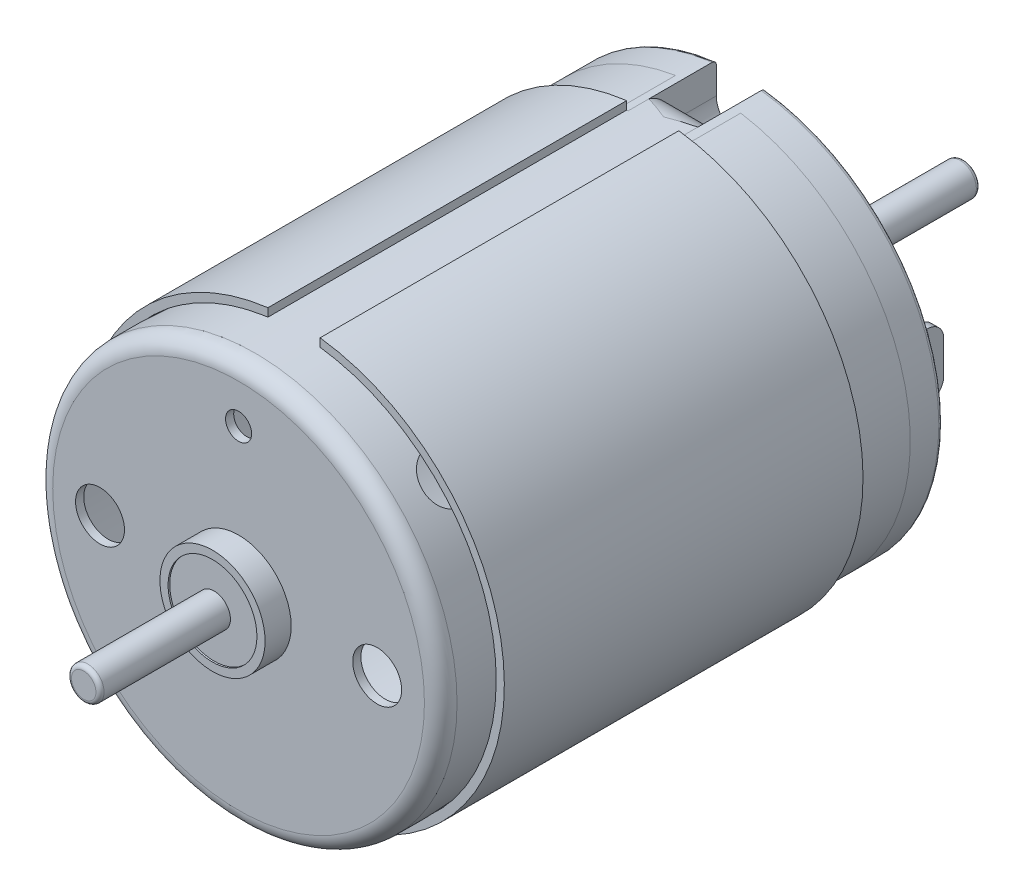
from build123d import *

# Parameters (mm, degrees)
SKETCH1_R            = 12.4
BASE_DEPTH           = 28.8
SKETCH2_R            = 12.4
BOSS_EXTRUDE2_DEPTH  = 2
SKETCH3_R            = 1
BOSS_EXTRUDE3_DEPTH  = 1.7
SKETCH4_R            = 0.75
CUT_EXTRUDE1_DEPTH   = 0.5
CUT_EXTRUDE2_DEPTH   = 5.4
BOSS_EXTRUDE4_DEPTH  = 5.4
BOSS_EXTRUDE5_DEPTH  = 1
BOSS_EXTRUDE15_DEPTH = 1.5
SKETCH14_R           = 13.384753183
SKETCH14_R_2         = 12.4
CUT_EXTRUDE3_DEPTH   = 33.5
FILLET2_R            = 1
FILLET2_OF_MIRROR2_R = 1
SKETCH15_W           = 0.5
SKETCH15_H           = 4
BOSS_EXTRUDE16_DEPTH = 4
SKETCH16_R           = 0.75
CUT_EXTRUDE4_DEPTH   = 0.5
FILLET3_R            = 1
SKETCH17_R           = 1
ENCODER_SHAFT_DEPTH  = 13.7
FILLET4_R            = 1
SKETCH18_R           = 3.225
SKETCH18_R_2         = 2.725
BOSS_EXTRUDE18_DEPTH = 1.6
SKETCH19_R           = 2.725
SKETCH19_R_2         = 1
BOSS_EXTRUDE19_DEPTH = 1.5
SKETCH20_R           = 0.8
SKETCH20_R_2         = 1.5
CUT_EXTRUDE5_DEPTH   = 0.5
SKETCH21_R           = 11.9
CUT_EXTRUDE6_DEPTH   = 23.5
SKETCH22_R           = 1
FRONT_SHAFT_DEPTH    = 9.5
SKETCH24_R           = 12.9
SKETCH24_R_2         = 12.4
BOSS_EXTRUDE21_DEPTH = 22
CUT_EXTRUDE8_DEPTH   = 22
CUT_EXTRUDE11_START  = -19.243354955
SKETCH26_R           = 1.5
CUT_EXTRUDE11_DEPTH  = 38.41627544
CIRPATTERN1_COUNT    = 2
CIRPATTERN1_ANGLE    = 90
FILLET5_R            = 0.25
FILLET6_R            = 0.25
FILLET7_R            = 0.25


with BuildPart() as part:
    # Sketch1 → Base (new body)
    with BuildSketch(Plane.XY):
        Circle(SKETCH1_R)
    extrude(amount=BASE_DEPTH)


with BuildPart() as body_2:
    # Sketch2 → Boss-Extrude2 (new body)
    with BuildSketch(Plane(origin=(0, 0, 0), x_dir=(-1, 0, 0), z_dir=(0, 0, -1))):
        Circle(SKETCH2_R)
    extrude(amount=BOSS_EXTRUDE2_DEPTH)

    # Sketch3 → Boss-Extrude3 (add)
    with BuildSketch(Plane(origin=(0, 0, -2), x_dir=(-1, 0, 0), z_dir=(0, 0, -1))):
        with BuildLine():
            Line((-1.436140662, 4), (1.436140662, 4))
            ThreePointArc((1.436140662, 4), (4.25, 0), (1.436140662, -4))
            Line((1.436140662, -4), (-1.436140662, -4))
            ThreePointArc((-1.436140662, -4), (-4.25, 0), (-1.436140662, 4))
        make_face()
        Circle(SKETCH3_R, mode=Mode.SUBTRACT)
    extrude(amount=BOSS_EXTRUDE3_DEPTH)

    # Sketch4 → Cut-Extrude1 (cut)
    with BuildSketch(Plane(origin=(0, 0, -2), x_dir=(-1, 0, 0), z_dir=(0, 0, -1))):
        with Locations((0, -5.203617714)):
            Circle(SKETCH4_R)
        with Locations((0, 5.203617714)):
            Circle(SKETCH4_R)
        with BuildLine():
            Line((-2, 7.071067812), (-2, 4.898979486))
            ThreePointArc((-2, 4.898979486), (-2.073598567, 4.637863002), (-2.272727273, 4.453617714))
            ThreePointArc((-2.272727273, 4.453617714), (-5, 0), (-2.272727273, -4.453617714))
            ThreePointArc((-2.272727273, -4.453617714), (-2.073598567, -4.637863002), (-2, -4.898979486))
            Line((-2, -4.898979486), (-2, -7.071067812))
            ThreePointArc((-2, -7.071067812), (-2.211324865, -7.479316102), (-2.666666667, -7.542472333))
            ThreePointArc((-2.666666667, -7.542472333), (-5.010229516, -6.236794064), (-6.790369935, -4.229760766))
            Line((-6.790369935, -4.229760766), (-9.5, -4.229760766))
            ThreePointArc((-9.5, -4.229760766), (-9.853553391, -4.083314157), (-10, -3.729760766))
            Line((-10, -3.729760766), (-10, 3.729760766))
            ThreePointArc((-10, 3.729760766), (-9.853553391, 4.083314157), (-9.5, 4.229760766))
            Line((-9.5, 4.229760766), (-6.790369935, 4.229760766))
            ThreePointArc((-6.790369935, 4.229760766), (-5.010229516, 6.236794064), (-2.666666667, 7.542472333))
            ThreePointArc((-2.666666667, 7.542472333), (-2.211324865, 7.479316102), (-2, 7.071067812))
        make_face()
        with BuildLine():
            Line((6.790369935, -4.229760766), (9.5, -4.229760766))
            ThreePointArc((9.5, -4.229760766), (9.853553391, -4.083314157), (10, -3.729760766))
            Line((10, -3.729760766), (10, 3.729760766))
            ThreePointArc((10, 3.729760766), (9.853553391, 4.083314157), (9.5, 4.229760766))
            Line((9.5, 4.229760766), (6.790369935, 4.229760766))
            ThreePointArc((6.790369935, 4.229760766), (5.010229516, 6.236794064), (2.666666667, 7.542472333))
            ThreePointArc((2.666666667, 7.542472333), (2.211324865, 7.479316102), (2, 7.071067812))
            Line((2, 7.071067812), (2, 4.898979486))
            ThreePointArc((2, 4.898979486), (2.073598567, 4.637863002), (2.272727273, 4.453617714))
            ThreePointArc((2.272727273, 4.453617714), (5, 0), (2.272727273, -4.453617714))
            ThreePointArc((2.272727273, -4.453617714), (2.073598567, -4.637863002), (2, -4.898979486))
            Line((2, -4.898979486), (2, -7.071067812))
            ThreePointArc((2, -7.071067812), (2.211324865, -7.479316102), (2.666666667, -7.542472333))
            ThreePointArc((2.666666667, -7.542472333), (5.010229516, -6.236794064), (6.790369935, -4.229760766))
        make_face()
    extrude(amount=-CUT_EXTRUDE1_DEPTH, mode=Mode.SUBTRACT)


with BuildPart() as cut_extrude2_tool:
    # Sketch5 → Cut-Extrude2 (new body)
    with BuildSketch(Plane(origin=(0, 0, -2), x_dir=(-1, 0, 0), z_dir=(0, 0, -1))):
        with BuildLine():
            Line((-2, 12.237646833), (-2, 10.4))
            ThreePointArc((-2, 10.4), (0, 8.4), (2, 10.4))
            Line((2, 10.4), (2, 12.237646833))
            ThreePointArc((2, 12.237646833), (0, 12.4), (-2, 12.237646833))
        make_face()
        with BuildLine():
            Line((2, -10.4), (2, -12.237646833))
            ThreePointArc((2, -12.237646833), (0, -12.4), (-2, -12.237646833))
            Line((-2, -12.237646833), (-2, -10.4))
            ThreePointArc((-2, -10.4), (0, -8.4), (2, -10.4))
        make_face()
    extrude(amount=-CUT_EXTRUDE2_DEPTH)


with BuildPart() as part_1:
    add(part.part)

    # Cut-Extrude2: cut by cut_extrude2_tool
    add(cut_extrude2_tool.part, mode=Mode.SUBTRACT)

    # Sketch11 → Boss-Extrude15 (add, symmetric)
    with BuildSketch(Plane(origin=(0, 0, 0), x_dir=(0, 0, -1), z_dir=(1, 0, 0))):
        with BuildLine():
            Line((-3.4, 12.4), (-2.728427125, 12.4))
            ThreePointArc((-2.728427125, 12.4), (-1.96306026, 12.247759065), (-1.314213562, 11.814213562))
            Line((-1.314213562, 11.814213562), (0.221320344, 10.278679656))
            Line((0.221320344, 10.278679656), (-0.309009742, 9.748349571))
            Line((-0.309009742, 9.748349571), (-1.624873734, 11.064213562))
            ThreePointArc((-1.624873734, 11.064213562), (-2.273720432, 11.497759065), (-3.039087297, 11.65))
            Line((-3.039087297, 11.65), (-3.4, 11.65))
            Line((-3.4, 11.65), (-3.4, 12.4))
        make_face()
    boss_extrude15 = extrude(amount=BOSS_EXTRUDE15_DEPTH, both=True)

    # Sketch14 → Cut-Extrude3 (cut, through all)
    with BuildSketch(Plane.XY.offset(28.8)):
        Circle(SKETCH14_R)
        Circle(SKETCH14_R_2, mode=Mode.SUBTRACT)
    cut_extrude3 = extrude(amount=-CUT_EXTRUDE3_DEPTH, mode=Mode.SUBTRACT)

    # Fillet2
    fillet2_edges = [part_1.edges().sort_by_distance(p)[0] for p in [
        (-1.5, 10.013514613, 0.043844699),
        (1.5, 10.013514613, 0.043844699),
    ]]
    fillet(fillet2_edges, radius=FILLET2_R)

    # Mirror2: Boss-Extrude15 across plane
    add(boss_extrude15.mirror(Plane.ZX))

    # Mirror2 2: Cut-Extrude3 across plane
    add(cut_extrude3.mirror(Plane.ZX), mode=Mode.SUBTRACT)

    # Fillet2 of Mirror2
    fillet2_of_mirror2_edges = [part_1.edges().sort_by_distance(p)[0] for p in [
        (-1.5, -10.013514613, 0.043844699),
        (1.5, -10.013514613, 0.043844699),
    ]]
    fillet(fillet2_of_mirror2_edges, radius=FILLET2_OF_MIRROR2_R)

    # Fillet4
    fillet4_edges = [part_1.edges().sort_by_distance(p)[0] for p in [
        (-12.4, 0, 28.8),
    ]]
    fillet(fillet4_edges, radius=FILLET4_R)

    # Sketch18 → Boss-Extrude18 (add)
    with BuildSketch(Plane.XY.offset(28.8)):
        Circle(SKETCH18_R)
        Circle(SKETCH18_R_2, mode=Mode.SUBTRACT)
    extrude(amount=BOSS_EXTRUDE18_DEPTH)

    # Sketch20 → Cut-Extrude5 (cut)
    with BuildSketch(Plane.XY.offset(28.8)):
        with Locations((0, 9)):
            Circle(SKETCH20_R)
        with Locations((-8.5, 0)):
            Circle(SKETCH20_R_2)
        with Locations((8.5, 0)):
            Circle(SKETCH20_R_2)
    extrude(amount=-CUT_EXTRUDE5_DEPTH, mode=Mode.SUBTRACT)

    # Sketch21 → Cut-Extrude6 (cut)
    with BuildSketch(Plane.XY.offset(28.3)):
        Circle(SKETCH21_R)
    extrude(amount=-CUT_EXTRUDE6_DEPTH, mode=Mode.SUBTRACT)



with BuildPart() as body_2_1:
    add(body_2.part)

    # Cut-Extrude2: cut by cut_extrude2_tool
    add(cut_extrude2_tool.part, mode=Mode.SUBTRACT)

    # Sketch6 → Boss-Extrude4 (add)
    with BuildSketch(Plane(origin=(0, 0, -2), x_dir=(-1, 0, 0), z_dir=(0, 0, -1))):
        with BuildLine():
            Line((-2, 10.4), (-2, 12.237646833))
            ThreePointArc((-2, 12.237646833), (-1.750363012, 12.275839251), (-1.5, 12.308939841))
            Line((-1.5, 12.308939841), (-1.5, 10.4))
            ThreePointArc((-1.5, 10.4), (0, 8.9), (1.5, 10.4))
            Line((1.5, 10.4), (1.5, 12.308939841))
            ThreePointArc((1.5, 12.308939841), (1.750363012, 12.275839251), (2, 12.237646833))
            Line((2, 12.237646833), (2, 10.4))
            ThreePointArc((2, 10.4), (0, 8.4), (-2, 10.4))
        make_face()
    boss_extrude4 = extrude(amount=-BOSS_EXTRUDE4_DEPTH)

    # Sketch7 → Boss-Extrude5 (add)
    with BuildSketch(Plane(origin=(0, 0, 3.4), x_dir=(-1, 0, 0), z_dir=(0, 0, -1))):
        with BuildLine():
            Line((-1.5, 10.4), (-1.5, 11.553029906))
            ThreePointArc((-1.5, 11.553029906), (0, 11.65), (1.5, 11.553029906))
            Line((1.5, 11.553029906), (1.5, 10.4))
            ThreePointArc((1.5, 10.4), (0, 8.9), (-1.5, 10.4))
        make_face()
    boss_extrude5 = extrude(amount=BOSS_EXTRUDE5_DEPTH)

    # Mirror1: Boss-Extrude4, Boss-Extrude5 across plane
    add(boss_extrude4.mirror(Plane.ZX))
    add(boss_extrude5.mirror(Plane.ZX))

    # Sketch15 → Boss-Extrude16 (add)
    with BuildSketch(Plane(origin=(0, 0, -1.5), x_dir=(-1, 0, 0), z_dir=(0, 0, -1))):
        with Locations((-8.7, 0)):
            Rectangle(SKETCH15_W, SKETCH15_H)
        with Locations((8.7, 0)):
            Rectangle(SKETCH15_W, SKETCH15_H)
    extrude(amount=BOSS_EXTRUDE16_DEPTH)

    # Sketch16 → Cut-Extrude4 (cut)
    with BuildSketch(Plane(origin=(8.95, 0, 0), x_dir=(0, 0, -1), z_dir=(1, 0, 0))):
        with Locations((3.5, 0)):
            Circle(SKETCH16_R)
    cut_extrude4 = extrude(amount=-CUT_EXTRUDE4_DEPTH, mode=Mode.SUBTRACT)

    # Fillet3
    fillet3_edges = [body_2_1.edges().sort_by_distance(p)[0] for p in [
        (8.7, -2, -5.5),
        (8.7, 2, -5.5),
        (-8.7, 2, -5.5),
        (-8.7, -2, -5.5),
    ]]
    fillet(fillet3_edges, radius=FILLET3_R)

    # Mirror3: Cut-Extrude4 across plane
    add(cut_extrude4.mirror(Plane(origin=(0, 0, 0), x_dir=(0, 0, 1), z_dir=(1, 0, 0))), mode=Mode.SUBTRACT)

    # Fillet5
    fillet5_edges = [body_2_1.edges().sort_by_distance(p)[0] for p in [
        (12.397428335, 0.252528559, -2),
        (-12.397428335, 0.252528559, -2),
    ]]
    fillet(fillet5_edges, radius=FILLET5_R)


with BuildPart() as body_3:
    # Sketch17 → Encoder Shaft (new body)
    with BuildSketch(Plane(origin=(0, 0, -2), x_dir=(-1, 0, 0), z_dir=(0, 0, -1))):
        Circle(SKETCH17_R)
    extrude(amount=ENCODER_SHAFT_DEPTH)

    # Fillet7
    fillet7_edges = [body_3.edges().sort_by_distance(p)[0] for p in [
        (1, 0, -15.7),
    ]]
    fillet(fillet7_edges, radius=FILLET7_R)


with BuildPart() as body_4:
    # Sketch19 → Boss-Extrude19 (new body)
    with BuildSketch(Plane.XY.offset(28.8)):
        Circle(SKETCH19_R)
        Circle(SKETCH19_R_2, mode=Mode.SUBTRACT)
    extrude(amount=BOSS_EXTRUDE19_DEPTH)


with BuildPart() as part_2:
    add(part_1.part)

    add(body_4.part)  # Front Shaft merges body 4
    # Sketch22 → Front Shaft (add)
    with BuildSketch(Plane.XY.offset(28.8)):
        Circle(SKETCH22_R)
    extrude(amount=FRONT_SHAFT_DEPTH)

    # Sketch26 → Cut-Extrude11 (cut)
    with BuildSketch(Plane(origin=(0, 0, 0), x_dir=(0.707106781, 0.707106781, 0), z_dir=(-0.707106781, 0.707106781, 0)).offset(CUT_EXTRUDE11_START)):
        with Locations((0, -24.8)):
            Circle(SKETCH26_R)
    cut_extrude11 = extrude(amount=CUT_EXTRUDE11_DEPTH, mode=Mode.SUBTRACT)

    # CirPattern1: Cut-Extrude11 ×2 about axis
    cirpattern1_axis = Axis((0, 0, 38.3), (0, 0, -1))
    for i in range(1, CIRPATTERN1_COUNT):
        add(cut_extrude11.rotate(cirpattern1_axis, i * CIRPATTERN1_ANGLE / (CIRPATTERN1_COUNT - 1)), mode=Mode.SUBTRACT)

    # Fillet6
    fillet6_edges = [part_2.edges().sort_by_distance(p)[0] for p in [
        (-1, 0, 38.3),
    ]]
    fillet(fillet6_edges, radius=FILLET6_R)


with BuildPart() as body_4_2:
    # Sketch24 → Boss-Extrude21 (new body)
    with BuildSketch(Plane.XY.offset(25.4)):
        Circle(SKETCH24_R)
        Circle(SKETCH24_R_2, mode=Mode.SUBTRACT)
    extrude(amount=-BOSS_EXTRUDE21_DEPTH)

    # Sketch25 → Cut-Extrude8 (cut)
    with BuildSketch(Plane.XY.offset(25.4)):
        with BuildLine():
            Line((-1.6, 12.800390619), (-1.6, 12.296340919))
            ThreePointArc((-1.6, 12.296340919), (0, 12.4), (1.6, 12.296340919))
            Line((1.6, 12.296340919), (1.6, 12.800390619))
            ThreePointArc((1.6, 12.800390619), (0, 12.9), (-1.6, 12.800390619))
        make_face()
    extrude(amount=-CUT_EXTRUDE8_DEPTH, mode=Mode.SUBTRACT)


solid = Compound([body_2_1.part, body_3.part, part_2.part, body_4_2.part])
